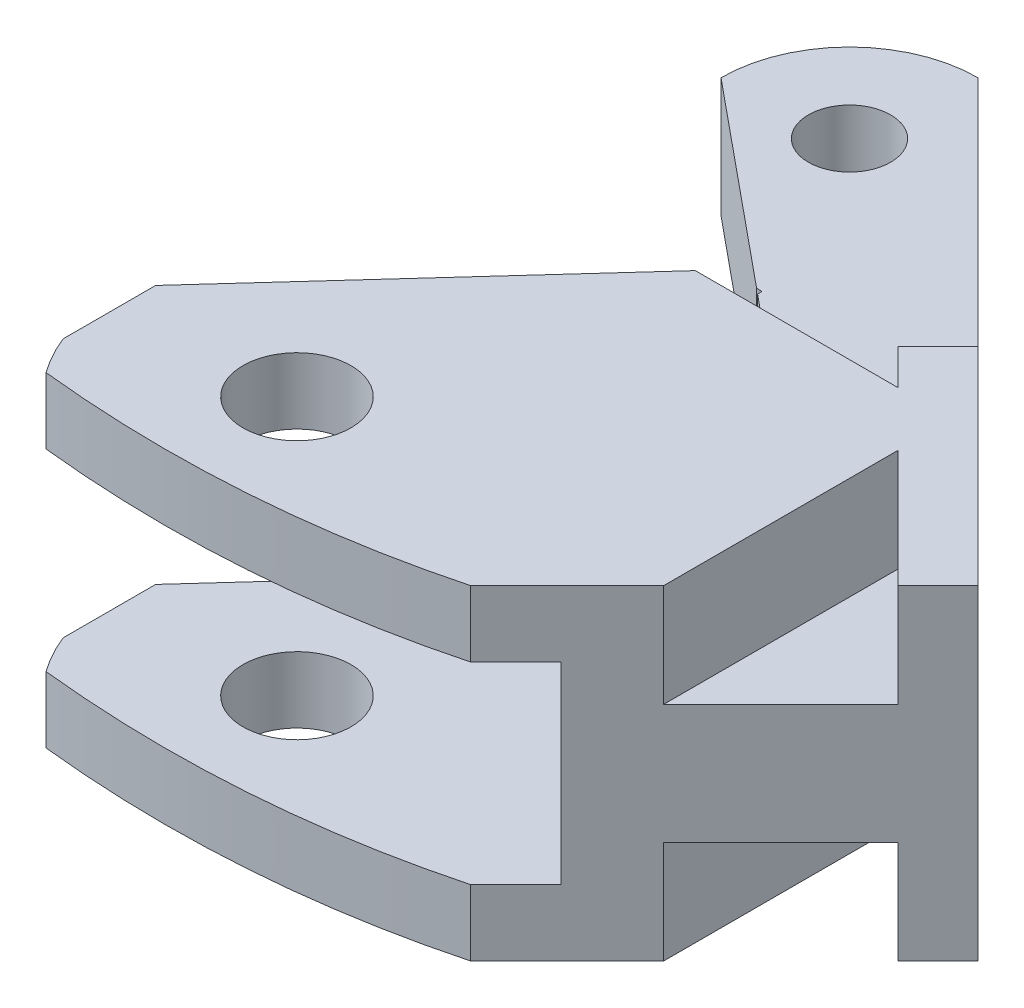
from build123d import *

# Parameters (mm, degrees)
SKETCH_1_R           = 1.6
EXTRUDE_1_DEPTH      = 4.65
SKETCH_7_W           = 9
SKETCH_7_H           = 19
EXTRUDE_4_DEPTH      = 4
SKETCH_8_W           = 9
SKETCH_8_H           = 19
EXTRUDE_5_DEPTH      = 4
SKETCH_9_W           = 16
SKETCH_9_H           = 7.5
CUT_EXTRUDE_3_DEPTH  = 9
SKETCH_11_R          = 2.1
CUT_EXTRUDE_5_DEPTH  = 26.4
EXTRUDE_6_DEPTH      = 9
SKETCH_13_W          = 19
SKETCH_13_H          = 12.65
EXTRUDE_7_DEPTH      = 2
SKETCH_15_W          = 7.596607022
SKETCH_15_H          = 7.5
CUT_EXTRUDE_6_DEPTH  = 8
CUT_EXTRUDE_7_DEPTH  = 8
EXTRUDE_8_DEPTH      = 4.65
CUT_EXTRUDE_9_DEPTH  = 4.65
SKETCH_20_W          = 5.380169682
SKETCH_20_H          = 3
CUT_EXTRUDE_10_DEPTH = 7.5
CUT_EXTRUDE_11_DEPTH = 4.65
CUT_EXTRUDE_13_DEPTH = 13
CUT_EXTRUDE_15_DEPTH = 13
SKETCH_26_W          = 18.396488504
SKETCH_26_H          = 12.65
EXTRUDE_9_DEPTH      = 2.2
SKETCH_28_W          = 2.5
SKETCH_28_H          = 12.65
CUT_EXTRUDE_17_DEPTH = 18
CUT_EXTRUDE_18_DEPTH = 14
SKETCH_31_W          = 5
SKETCH_31_H          = 12.65
CUT_EXTRUDE_19_DEPTH = 20


with BuildPart() as part:
    # 草图1 → 凸台-拉伸1 (new body)
    with BuildSketch(Plane(origin=(0, 0, 0), x_dir=(1, 0, 0), z_dir=(0, 1, 0))):
        with BuildLine():
            Line((5, 0), (20, 0))
            Line((20, 0), (20, -16))
            Line((20, -16), (9, -16))
            Line((9, -16), (9, -35))
            Line((9, -35), (0, -35))
            Line((0, -35), (0, -27))
            Line((0, -27), (0, -5))
            ThreePointArc((0, -5), (1.464466094, -1.464466094), (5, 0))
        make_face()
        with Locations((4.55, -4.55)):
            Circle(SKETCH_1_R, mode=Mode.SUBTRACT)
    extrude(amount=EXTRUDE_1_DEPTH)

    # 草图7 → 凸台-拉伸4 (add)
    with BuildSketch(Plane(origin=(0, 4.65, 0), x_dir=(1, 0, 0), z_dir=(0, 1, 0))):
        with Locations((4.5, -25.5)):
            Rectangle(SKETCH_7_W, SKETCH_7_H)
    extrude(amount=EXTRUDE_4_DEPTH)

    # 草图8 → 凸台-拉伸5 (add)
    with BuildSketch(Plane.XZ):
        with Locations((4.5, 25.5)):
            Rectangle(SKETCH_8_W, SKETCH_8_H)
    extrude(amount=EXTRUDE_5_DEPTH)

    # 草图9 → 切除-拉伸3 (cut)
    with BuildSketch(Plane.ZY):
        with Locations((27, 2.325)):
            Rectangle(SKETCH_9_W, SKETCH_9_H)
    extrude(amount=-CUT_EXTRUDE_3_DEPTH, mode=Mode.SUBTRACT)

    # 草图11 → 切除-拉伸5 (cut)
    with BuildSketch(Plane(origin=(0, 8.65, 0), x_dir=(1, 0, 0), z_dir=(0, 1, 0))):
        with Locations((6.5, -28)):
            Circle(SKETCH_11_R)
    extrude(amount=-CUT_EXTRUDE_5_DEPTH, mode=Mode.SUBTRACT)

    # 草图12 → 凸台-拉伸6 (add)
    with BuildSketch(Plane(origin=(9, 0, 0), x_dir=(0, 0, -1), z_dir=(1, 0, 0))):
        Polygon((-35, 8.65), (-35, 6.075), (-19, 6.075), (-19, -1.425), (-35, -1.425), (-35, -4), (-16, -4), (-16, 8.65), align=None)
    extrude(amount=EXTRUDE_6_DEPTH)

    # 草图13 → 凸台-拉伸7 (add)
    with BuildSketch(Plane(origin=(18, 0, 0), x_dir=(0, 0, -1), z_dir=(1, 0, 0))):
        with Locations((-25.5, 2.325)):
            Rectangle(SKETCH_13_W, SKETCH_13_H)
    extrude(amount=EXTRUDE_7_DEPTH)

    # 草图15 → 切除-拉伸6 (cut)
    with BuildSketch(Plane.ZY):
        with Locations((15.201696489, 2.325)):
            Rectangle(SKETCH_15_W, SKETCH_15_H)
    extrude(amount=-CUT_EXTRUDE_6_DEPTH, mode=Mode.SUBTRACT)

    # 草图16 → 切除-拉伸7 (cut)
    with BuildSketch(Plane(origin=(0, 4.65, 0), x_dir=(1, 0, 0), z_dir=(0, 1, 0))):
        Polygon((0, -5), (5.890898071, -11.403392978), (0, -11.403392978), align=None)
    extrude(amount=-CUT_EXTRUDE_7_DEPTH, mode=Mode.SUBTRACT)

    # 草图17 → 凸台-拉伸8 (add)
    with BuildSketch(Plane.XZ):
        with BuildLine():
            Line((20, 35), (20, 15))
            Line((20, 15), (31.064630957, 26.064630957))
            ThreePointArc((31.064630957, 26.064630957), (26.002686727, 31.114774273), (20, 35))
        make_face()
    extrude(amount=-EXTRUDE_8_DEPTH)

    # 草图19 → 切除-拉伸9 (cut)
    with BuildSketch(Plane(origin=(0, 4.65, 0), x_dir=(1, 0, 0), z_dir=(0, 1, 0))):
        Polygon((20, -15), (5, 0), (20, 0), align=None)
    extrude(amount=-CUT_EXTRUDE_9_DEPTH, mode=Mode.SUBTRACT)

    # 草图20 → 切除-拉伸10 (cut)
    with BuildSketch(Plane(origin=(0, -1.425, 0), x_dir=(1, 0, 0), z_dir=(0, 1, 0))):
        with Locations((10.690084841, -17.5)):
            Rectangle(SKETCH_20_W, SKETCH_20_H)
    extrude(amount=CUT_EXTRUDE_10_DEPTH, mode=Mode.SUBTRACT)

    # 草图21 → 切除-拉伸11 (cut)
    with BuildSketch(Plane.XZ):
        Polygon((13.380169682, 16), (0, 5), (8, 16), align=None)
    extrude(amount=-CUT_EXTRUDE_11_DEPTH, mode=Mode.SUBTRACT)

    # 草图22 → 切除-拉伸13 (cut)
    with BuildSketch(Plane(origin=(0, 8.65, 0), x_dir=(1, 0, 0), z_dir=(0, 1, 0))):
        Polygon((0, -16), (10, -16), (0, -27), align=None)
    extrude(amount=-CUT_EXTRUDE_13_DEPTH, mode=Mode.SUBTRACT)

    # 草图23 → 切除-拉伸15 (cut)
    with BuildSketch(Plane(origin=(0, 8.65, 0), x_dir=(1, 0, 0), z_dir=(0, 1, 0))):
        with BuildLine():
            Line((6.5, -35), (0, -35))
            Line((0, -35), (0, -30.598076211))
            ThreePointArc((0, -30.598076211), (2.574858823, -33.79596987), (6.5, -35))
        make_face()
    extrude(amount=-CUT_EXTRUDE_15_DEPTH, mode=Mode.SUBTRACT)

    # 草图26 → 凸台-拉伸9 (add)
    with BuildSketch(Plane(origin=(2.5, 0, -2.5), x_dir=(-0.707106781, 0, -0.707106781), z_dir=(0.707106781, 0, -0.707106781))):
        with Locations((-31.198244252, 2.325)):
            Rectangle(SKETCH_26_W, SKETCH_26_H)
    extrude(amount=-EXTRUDE_9_DEPTH)

    # 草图28 → 切除-拉伸17 (cut)
    with BuildSketch(Plane(origin=(2.5, 0, -2.5), x_dir=(-0.707106781, 0, -0.707106781), z_dir=(0.707106781, 0, -0.707106781))):
        with Locations((-39.646488504, 2.325)):
            Rectangle(SKETCH_28_W, SKETCH_28_H)
    extrude(amount=-CUT_EXTRUDE_17_DEPTH, mode=Mode.SUBTRACT)

    # 草图29 → 切除-拉伸18 (cut)
    with BuildSketch(Plane.XZ.offset(4)):
        with BuildLine():
            Line((29.650417395, 24.650417395), (19.300834789, 35))
            Line((19.300834789, 35), (1.773611639, 35))
            Line((1.773611639, 35), (0.803925841, 32.06875155))
            add(Edge.make_bspline(
                [(29.650417395, 24.650417395), (16.711479186, 33.756910479), (0.803925841, 32.06875155)],
                knots=[0, 0, 0, 1, 1, 1], degree=2))
        make_face()
    extrude(amount=-CUT_EXTRUDE_18_DEPTH, mode=Mode.SUBTRACT)

    # 草图31 → 切除-拉伸19 (cut)
    with BuildSketch(Plane(origin=(2.5, 0, -2.5), x_dir=(-0.707106781, 0, -0.707106781), z_dir=(0.707106781, 0, -0.707106781))):
        with Locations((-35.896488504, 2.325)):
            Rectangle(SKETCH_31_W, SKETCH_31_H)
    extrude(amount=-CUT_EXTRUDE_19_DEPTH, mode=Mode.SUBTRACT)


solid = part.part
